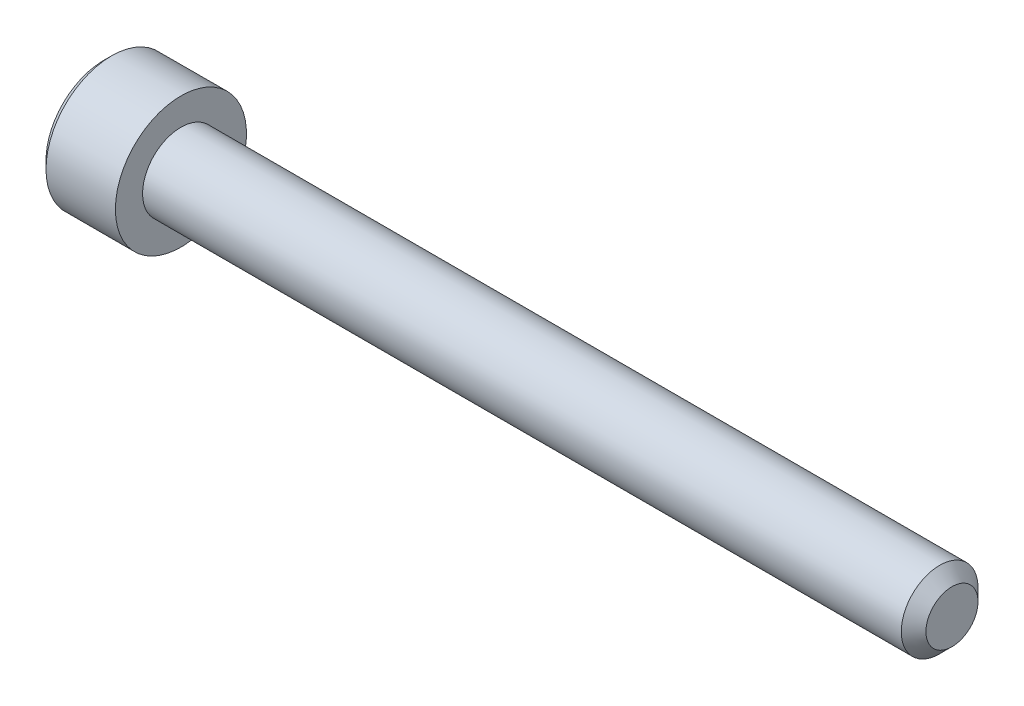
from build123d import *

# Parameters (mm, degrees)
CHAMFER1_SIZE      = 0.8
CHAMFER2_SIZE      = 0.5
CUT_EXTRUDE1_DEPTH = 2.5
CHAMFER3_SIZE      = 0.4


with BuildPart() as part:
    # Sketch1 → Revolve1 (revolve)
    with BuildSketch(Plane.XY):
        Polygon((0, 0), (0, 4.25), (5, 4.25), (5, 2.488), (55, 2.488), (55, 0), align=None)
    revolve(axis=Axis((-88.705490849, 0, 0), (1, 0, 0)))

    # Chamfer1
    chamfer1_edges = [part.edges().sort_by_distance(p)[0] for p in [
        (55, -2.488, 0),
    ]]
    chamfer(chamfer1_edges, length=CHAMFER1_SIZE)

    # Chamfer2
    chamfer2_edges = [part.edges().sort_by_distance(p)[0] for p in [
        (0, -4.25, 0),
    ]]
    chamfer(chamfer2_edges, length=CHAMFER2_SIZE)

    # Sketch3 → Cut-Extrude1 (cut)
    with BuildSketch(Plane(origin=(0, 0, 0), x_dir=(0, 0, -1), z_dir=(1, 0, 0))):
        Polygon((-2.309401077, 0), (-1.154700538, -2), (1.154700538, -2), (2.309401077, 0), (1.154700538, 2), (-1.154700538, 2), align=None)
    extrude(amount=CUT_EXTRUDE1_DEPTH, mode=Mode.SUBTRACT)

    # Chamfer3
    chamfer3_edges = [part.edges().sort_by_distance(p)[0] for p in [
        (0, 2, 0),
        (0, 1, 1.732050808),
        (0, -1, 1.732050808),
        (0, -2, 0),
        (0, -1, -1.732050808),
        (0, 1, -1.732050808),
    ]]
    chamfer(chamfer3_edges, length=CHAMFER3_SIZE)


solid = part.part
